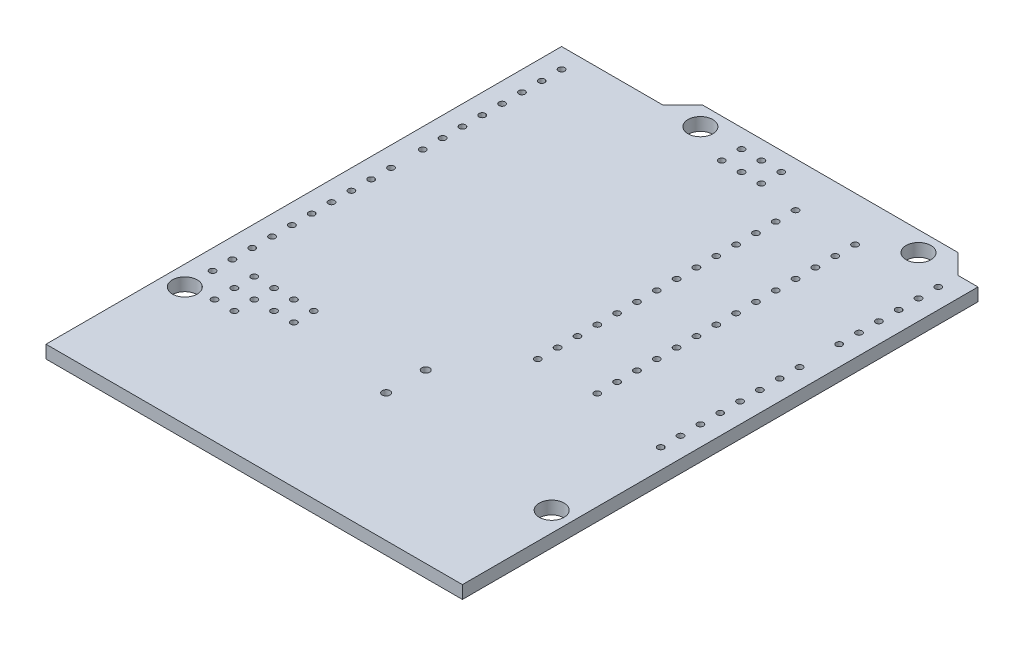
from build123d import *

# Parameters (mm, degrees)
SKETCH1_R           = 1.5875
BOSS_EXTRUDE1_DEPTH = 1.65
SKETCH2_R           = 0.4
CUT_EXTRUDE1_DEPTH  = 1.65
SKETCH3_R           = 0.4
CUT_EXTRUDE2_DEPTH  = 1.65
LPATTERN1_COUNT     = 15
LPATTERN1_PITCH     = 2.54
SKETCH4_R           = 0.4
CUT_EXTRUDE3_DEPTH  = 1.65
LPATTERN2_COUNT     = 10
LPATTERN2_PITCH     = 2.54
LPATTERN3_COUNT     = 8
LPATTERN3_PITCH     = 2.54
SKETCH5_R           = 0.4
SKETCH5_R_2         = 0.5
CUT_EXTRUDE4_DEPTH  = 10
SKETCH6_R           = 0.4
CUT_EXTRUDE5_DEPTH  = 10


with BuildPart() as part:
    # Sketch1 → Boss-Extrude1 (new body)
    with BuildSketch(Plane(origin=(0, 0, 0), x_dir=(1, 0, 0), z_dir=(0, 1, 0))):
        Polygon((0, 0), (-53.34, 0), (-53.34, 66.04), (-40.386, 66.04), (-37.846, 68.58), (-5.08, 68.58), (-2.54, 66.04), (0, 66.04), align=None)
        with Locations(Location((-7.62, 66.04, 0), (0, 0, 270))):  # turned: the seam where the file's is
            Circle(SKETCH1_R, mode=Mode.SUBTRACT)
        with Locations(Location((-35.56, 66.04, 0), (0, 0, 270))):  # turned: the seam where the file's is
            Circle(SKETCH1_R, mode=Mode.SUBTRACT)
        with Locations(Location((-2.54, 13.97, 0), (0, 0, 270))):  # turned: the seam where the file's is
            Circle(SKETCH1_R, mode=Mode.SUBTRACT)
        with Locations(Location((-50.8, 15.24, 0), (0, 0, 270))):  # turned: the seam where the file's is
            Circle(SKETCH1_R, mode=Mode.SUBTRACT)
    extrude(amount=-BOSS_EXTRUDE1_DEPTH)

    # Sketch2 → Cut-Extrude1 (cut)
    with BuildSketch(Plane(origin=(0, 0, 0), x_dir=(1, 0, 0), z_dir=(0, 1, 0))):
        with Locations(Location((-2.54, 27.94, 0), (0, 0, 270))):  # turned: the seam where the file's is
            Circle(SKETCH2_R)
    cut_extrude1 = extrude(amount=-CUT_EXTRUDE1_DEPTH, mode=Mode.SUBTRACT)

    # Sketch3 → Cut-Extrude2 (cut)
    with BuildSketch(Plane(origin=(0, 0, 0), x_dir=(1, 0, 0), z_dir=(0, 1, 0))):
        with Locations(Location((-50.8, 18.796, 0), (0, 0, 270))):  # turned: the seam where the file's is
            Circle(SKETCH3_R)
    cut_extrude2 = extrude(amount=-CUT_EXTRUDE2_DEPTH, mode=Mode.SUBTRACT)

    # LPattern1: Cut-Extrude1 ×15, 1 skipped
    with Locations(*[(0, 0, -i * LPATTERN1_PITCH) for i in range(1, LPATTERN1_COUNT) if i not in (8,)]):
        add(cut_extrude1, mode=Mode.SUBTRACT)

    # Sketch4 → Cut-Extrude3 (cut)
    with BuildSketch(Plane(origin=(0, 0, 0), x_dir=(1, 0, 0), z_dir=(0, 1, 0))):
        with Locations(Location((-50.8, 45.72, 0), (0, 0, 270))):  # turned: the seam where the file's is
            Circle(SKETCH4_R)
    cut_extrude3 = extrude(amount=-CUT_EXTRUDE3_DEPTH, mode=Mode.SUBTRACT)

    # LPattern2: Cut-Extrude2 ×10
    with Locations(*[(0, 0, -i * LPATTERN2_PITCH) for i in range(1, LPATTERN2_COUNT)]):
        add(cut_extrude2, mode=Mode.SUBTRACT)

    # LPattern3: Cut-Extrude3 ×8
    with Locations(*[(0, 0, -i * LPATTERN3_PITCH) for i in range(1, LPATTERN3_COUNT)]):
        add(cut_extrude3, mode=Mode.SUBTRACT)

    # Sketch5 → Cut-Extrude4 (cut)
    with BuildSketch(Plane(origin=(0, 0, 0), x_dir=(1, 0, 0), z_dir=(0, 1, 0))):
        with Locations(Location((-30.43, 66.18, 0), (0, 0, 270))):  # turned: the seam where the file's is
            Circle(SKETCH5_R)
        with Locations(Location((-27.89, 66.18, 0), (0, 0, 270))):  # turned: the seam where the file's is
            Circle(SKETCH5_R)
        with Locations(Location((-25.35, 66.18, 0), (0, 0, 270))):  # turned: the seam where the file's is
            Circle(SKETCH5_R)
        with Locations(Location((-25.35, 63.64, 0), (0, 0, 270))):  # turned: the seam where the file's is
            Circle(SKETCH5_R)
        with Locations(Location((-27.89, 63.64, 0), (0, 0, 270))):  # turned: the seam where the file's is
            Circle(SKETCH5_R)
        with Locations(Location((-30.43, 63.64, 0), (0, 0, 270))):  # turned: the seam where the file's is
            Circle(SKETCH5_R)
        with Locations(Location((-47.498, 15.748, 0), (0, 0, 270))):  # turned: the seam where the file's is
            Circle(SKETCH5_R)
        with Locations(Location((-47.498, 18.288, 0), (0, 0, 270))):  # turned: the seam where the file's is
            Circle(SKETCH5_R)
        with Locations(Location((-47.498, 20.828, 0), (0, 0, 270))):  # turned: the seam where the file's is
            Circle(SKETCH5_R)
        with Locations(Location((-44.958, 20.828, 0), (0, 0, 270))):  # turned: the seam where the file's is
            Circle(SKETCH5_R)
        with Locations(Location((-44.958, 18.288, 0), (0, 0, 270))):  # turned: the seam where the file's is
            Circle(SKETCH5_R)
        with Locations(Location((-44.958, 15.748, 0), (0, 0, 270))):  # turned: the seam where the file's is
            Circle(SKETCH5_R)
        with Locations(Location((-42.418, 18.288, 0), (0, 0, 270))):  # turned: the seam where the file's is
            Circle(SKETCH5_R)
        with Locations(Location((-42.418, 20.828, 0), (0, 0, 270))):  # turned: the seam where the file's is
            Circle(SKETCH5_R)
        with Locations(Location((-39.878, 20.828, 0), (0, 0, 270))):  # turned: the seam where the file's is
            Circle(SKETCH5_R)
        with Locations(Location((-39.878, 18.288, 0), (0, 0, 270))):  # turned: the seam where the file's is
            Circle(SKETCH5_R)
        with Locations(Location((-26.162, 21.463, 0), (0, 0, 270))):  # turned: the seam where the file's is
            Circle(SKETCH5_R_2)
        with Locations(Location((-26.162, 16.383, 0), (0, 0, 270))):  # turned: the seam where the file's is
            Circle(SKETCH5_R_2)
    extrude(amount=-CUT_EXTRUDE4_DEPTH, mode=Mode.SUBTRACT)

    # Sketch6 → Cut-Extrude5 (cut)
    with BuildSketch(Plane(origin=(0, 0, 0), x_dir=(1, 0, 0), z_dir=(0, 1, 0))):
        with Locations(Location((-20.193, 29.845, 0), (0, 0, 270))):  # turned: the seam where the file's is
            Circle(SKETCH6_R)
        with Locations(Location((-12.573, 29.845, 0), (0, 0, 270))):  # turned: the seam where the file's is
            Circle(SKETCH6_R)
        with Locations(Location((-20.193, 32.385, 0), (0, 0, 270))):  # turned: the seam where the file's is
            Circle(SKETCH6_R)
        with Locations(Location((-12.573, 32.385, 0), (0, 0, 270))):  # turned: the seam where the file's is
            Circle(SKETCH6_R)
        with Locations(Location((-20.193, 34.925, 0), (0, 0, 270))):  # turned: the seam where the file's is
            Circle(SKETCH6_R)
        with Locations(Location((-12.573, 34.925, 0), (0, 0, 270))):  # turned: the seam where the file's is
            Circle(SKETCH6_R)
        with Locations(Location((-20.193, 37.465, 0), (0, 0, 270))):  # turned: the seam where the file's is
            Circle(SKETCH6_R)
        with Locations(Location((-12.573, 37.465, 0), (0, 0, 270))):  # turned: the seam where the file's is
            Circle(SKETCH6_R)
        with Locations(Location((-20.193, 40.005, 0), (0, 0, 270))):  # turned: the seam where the file's is
            Circle(SKETCH6_R)
        with Locations(Location((-12.573, 40.005, 0), (0, 0, 270))):  # turned: the seam where the file's is
            Circle(SKETCH6_R)
        with Locations(Location((-20.193, 42.545, 0), (0, 0, 270))):  # turned: the seam where the file's is
            Circle(SKETCH6_R)
        with Locations(Location((-12.573, 42.545, 0), (0, 0, 270))):  # turned: the seam where the file's is
            Circle(SKETCH6_R)
        with Locations(Location((-20.193, 45.085, 0), (0, 0, 270))):  # turned: the seam where the file's is
            Circle(SKETCH6_R)
        with Locations(Location((-12.573, 45.085, 0), (0, 0, 270))):  # turned: the seam where the file's is
            Circle(SKETCH6_R)
        with Locations(Location((-20.193, 47.625, 0), (0, 0, 270))):  # turned: the seam where the file's is
            Circle(SKETCH6_R)
        with Locations(Location((-12.573, 47.625, 0), (0, 0, 270))):  # turned: the seam where the file's is
            Circle(SKETCH6_R)
        with Locations(Location((-20.193, 50.165, 0), (0, 0, 270))):  # turned: the seam where the file's is
            Circle(SKETCH6_R)
        with Locations(Location((-12.573, 50.165, 0), (0, 0, 270))):  # turned: the seam where the file's is
            Circle(SKETCH6_R)
        with Locations(Location((-20.193, 52.705, 0), (0, 0, 270))):  # turned: the seam where the file's is
            Circle(SKETCH6_R)
        with Locations(Location((-12.573, 52.705, 0), (0, 0, 270))):  # turned: the seam where the file's is
            Circle(SKETCH6_R)
        with Locations(Location((-20.193, 55.245, 0), (0, 0, 270))):  # turned: the seam where the file's is
            Circle(SKETCH6_R)
        with Locations(Location((-12.573, 55.245, 0), (0, 0, 270))):  # turned: the seam where the file's is
            Circle(SKETCH6_R)
        with Locations(Location((-20.193, 57.785, 0), (0, 0, 270))):  # turned: the seam where the file's is
            Circle(SKETCH6_R)
        with Locations(Location((-12.573, 57.785, 0), (0, 0, 270))):  # turned: the seam where the file's is
            Circle(SKETCH6_R)
        with Locations(Location((-20.193, 60.325, 0), (0, 0, 270))):  # turned: the seam where the file's is
            Circle(SKETCH6_R)
        with Locations(Location((-12.573, 60.325, 0), (0, 0, 270))):  # turned: the seam where the file's is
            Circle(SKETCH6_R)
        with Locations(Location((-20.193, 62.865, 0), (0, 0, 270))):  # turned: the seam where the file's is
            Circle(SKETCH6_R)
        with Locations(Location((-12.573, 62.865, 0), (0, 0, 270))):  # turned: the seam where the file's is
            Circle(SKETCH6_R)
    extrude(amount=-CUT_EXTRUDE5_DEPTH, mode=Mode.SUBTRACT)


solid = part.part
